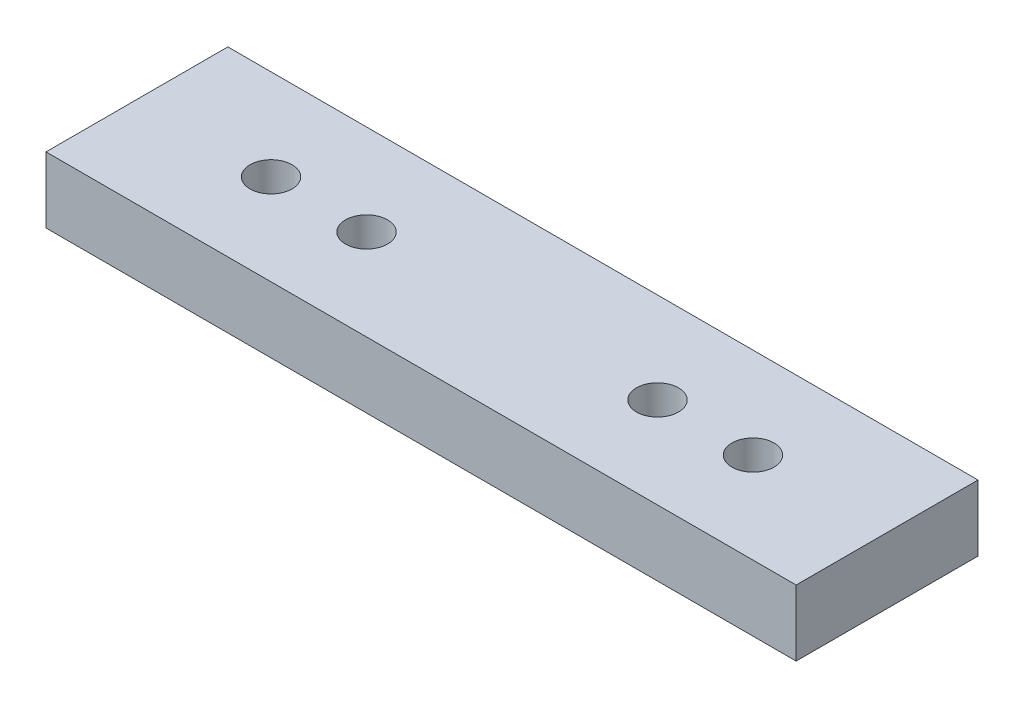
from build123d import *

# Parameters (mm, degrees)
SKETCH1_W           = 41.91
SKETCH1_H           = 10.16
BOSS_EXTRUDE1_DEPTH = 3.683
SKETCH2_2_R         = 1.174037675
CUT_EXTRUDE1_DEPTH  = 22.874252307


with BuildPart() as part:
    # Sketch1 → Boss-Extrude1 (new body)
    with BuildSketch(Plane(origin=(0, 0, 0), x_dir=(1, 0, 0), z_dir=(0, 1, 0))):
        Rectangle(SKETCH1_W, SKETCH1_H)
    extrude(amount=BOSS_EXTRUDE1_DEPTH)

    # Sketch2_2 → Cut-Extrude1 (cut, through all)
    with BuildSketch(Plane.XZ):
        with Locations((-13.462, 0)):
            Circle(SKETCH2_2_R)
        with Locations((-8.128, 0)):
            Circle(SKETCH2_2_R)
        with Locations((8.128, 0)):
            Circle(SKETCH2_2_R)
        with Locations((13.462, 0)):
            Circle(SKETCH2_2_R)
    extrude(amount=-CUT_EXTRUDE1_DEPTH, mode=Mode.SUBTRACT)


solid = part.part
